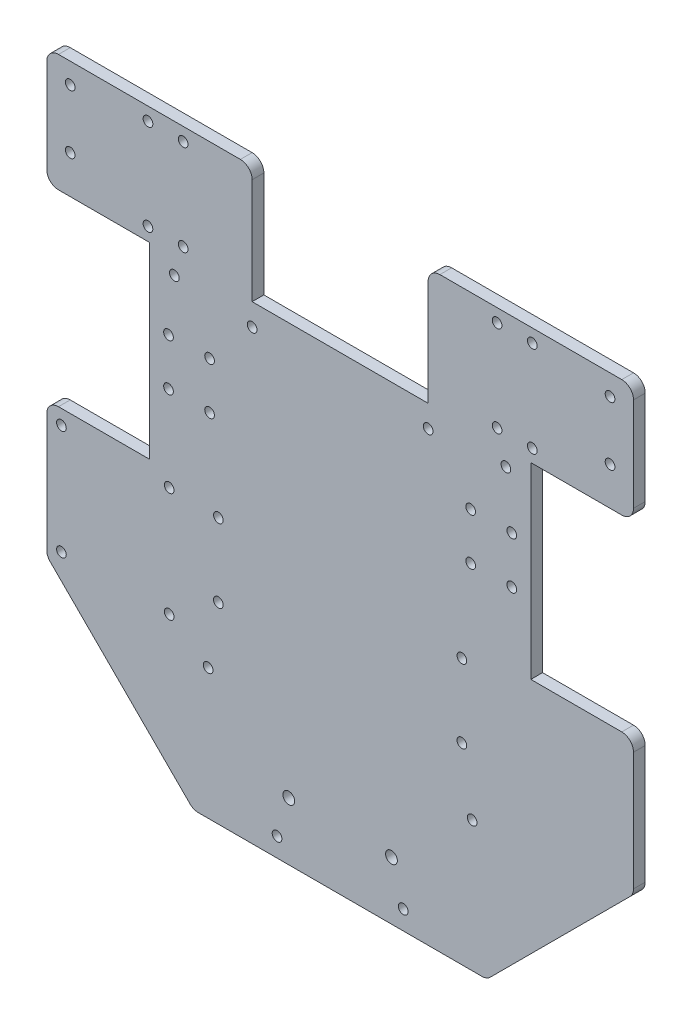
from build123d import *

# Parameters (mm, degrees)
EXTRUDE_1_DEPTH      = 4
SKETCH_4_R           = 1.65
CUT_EXTRUDE_5_DEPTH  = 10
SKETCH_5_R           = 1.65
CUT_EXTRUDE_6_DEPTH  = 10
SKETCH_6_R           = 1.65
CUT_EXTRUDE_7_DEPTH  = 10
SKETCH_7_R           = 1.65
CUT_EXTRUDE_8_DEPTH  = 10
SKETCH_8_R           = 2
CUT_EXTRUDE_9_DEPTH  = 10
SKETCH_9_R           = 1.65
CUT_EXTRUDE_10_DEPTH = 10
SKETCH_10_R          = 1.65
CUT_EXTRUDE_11_DEPTH = 10
SKETCH_11_R          = 1.65
CUT_EXTRUDE_12_DEPTH = 10
SKETCH_12_R          = 1.65
CUT_EXTRUDE_13_DEPTH = 10
FILLET_1_R           = 4
FILLET_2_R           = 4


with BuildPart() as part:
    # 草图1 → 凸台-拉伸1 (new body)
    with BuildSketch(Plane.XY):
        with BuildLine():
            Line((-96, 200), (-30, 200))
            Line((-30, 200), (-30, 160))
            Line((-30, 160), (30, 160))
            Line((30, 160), (30, 200))
            Line((30, 200), (96, 200))
            ThreePointArc((96, 200), (98.828427125, 198.828427125), (100, 196))
            Line((100, 196), (100, 160))
            Line((100, 160), (65, 160))
            Line((65, 160), (65, 96))
            Line((65, 96), (100, 96))
            Line((100, 96), (100, 50))
            Line((100, 50), (50, 0))
            Line((50, 0), (-50, 0))
            Line((-50, 0), (-100, 50))
            Line((-100, 50), (-100, 96))
            Line((-100, 96), (-65, 96))
            Line((-65, 96), (-65, 160))
            Line((-65, 160), (-100, 160))
            Line((-100, 160), (-100, 196))
            ThreePointArc((-100, 196), (-98.828427125, 198.828427125), (-96, 200))
        make_face()
    extrude(amount=EXTRUDE_1_DEPTH)

    # 草图4 → 切除-拉伸5 (cut)
    with BuildSketch(Plane(origin=(0, 0, 0), x_dir=(-1, 0, 0), z_dir=(0, 0, -1))):
        with Locations((56.5, 154.5)):
            Circle(SKETCH_4_R)
        with Locations((-56.5, 154.5)):
            Circle(SKETCH_4_R)
        with Locations((45, 44.5)):
            Circle(SKETCH_4_R)
        with Locations((-45, 44.5)):
            Circle(SKETCH_4_R)
    extrude(amount=-CUT_EXTRUDE_5_DEPTH, mode=Mode.SUBTRACT)

    # 草图5 → 切除-拉伸6 (cut)
    with BuildSketch(Plane(origin=(0, 0, 0), x_dir=(-1, 0, 0), z_dir=(0, 0, -1))):
        with Locations((41.5, 90.5)):
            Circle(SKETCH_5_R)
        with Locations((-41.5, 90.5)):
            Circle(SKETCH_5_R)
        with Locations((41.5, 65.5)):
            Circle(SKETCH_5_R)
        with Locations((-41.5, 65.5)):
            Circle(SKETCH_5_R)
    extrude(amount=-CUT_EXTRUDE_6_DEPTH, mode=Mode.SUBTRACT)

    # 草图6 → 切除-拉伸7 (cut)
    with BuildSketch(Plane(origin=(0, 0, 0), x_dir=(-1, 0, 0), z_dir=(0, 0, -1))):
        with Locations((58.26, 91)):
            Circle(SKETCH_6_R)
        with Locations((95, 91)):
            Circle(SKETCH_6_R)
        with Locations((58.26, 53.62)):
            Circle(SKETCH_6_R)
        with Locations((95, 53.62)):
            Circle(SKETCH_6_R)
    extrude(amount=-CUT_EXTRUDE_7_DEPTH, mode=Mode.SUBTRACT)

    # 草图7 → 切除-拉伸8 (cut)
    with BuildSketch(Plane(origin=(0, 0, 0), x_dir=(-1, 0, 0), z_dir=(0, 0, -1))):
        with Locations((-21.5, 6.5)):
            Circle(SKETCH_7_R)
        with Locations((21.5, 6.5)):
            Circle(SKETCH_7_R)
    extrude(amount=-CUT_EXTRUDE_8_DEPTH, mode=Mode.SUBTRACT)

    # 草图8 → 切除-拉伸9 (cut)
    with BuildSketch(Plane(origin=(0, 0, 0), x_dir=(-1, 0, 0), z_dir=(0, 0, -1))):
        with Locations((-17.5, 19.75)):
            Circle(SKETCH_8_R)
        with Locations((17.5, 19.75)):
            Circle(SKETCH_8_R)
    extrude(amount=-CUT_EXTRUDE_9_DEPTH, mode=Mode.SUBTRACT)

    # 草图9 → 切除-拉伸10 (cut)
    with BuildSketch(Plane(origin=(0, 0, 0), x_dir=(-1, 0, 0), z_dir=(0, 0, -1))):
        with Locations((-30, 152.5)):
            Circle(SKETCH_9_R)
        with Locations((30, 152.5)):
            Circle(SKETCH_9_R)
    extrude(amount=-CUT_EXTRUDE_10_DEPTH, mode=Mode.SUBTRACT)

    # 草图10 → 切除-拉伸11 (cut)
    with BuildSketch(Plane.XY.offset(4)):
        with Locations((-92, 193)):
            Circle(SKETCH_10_R)
        with Locations((-92, 173)):
            Circle(SKETCH_10_R)
        with Locations((92, 173)):
            Circle(SKETCH_10_R)
        with Locations((92, 193)):
            Circle(SKETCH_10_R)
    extrude(amount=-CUT_EXTRUDE_11_DEPTH, mode=Mode.SUBTRACT)

    # 草图11 → 切除-拉伸12 (cut)
    with BuildSketch(Plane.XY.offset(4)):
        with Locations((65.5, 164.5)):
            Circle(SKETCH_11_R)
        with Locations((53.5, 164.5)):
            Circle(SKETCH_11_R)
        with Locations((53.5, 195.5)):
            Circle(SKETCH_11_R)
        with Locations((65.5, 195.5)):
            Circle(SKETCH_11_R)
        with Locations((-65.5, 195.5)):
            Circle(SKETCH_11_R)
        with Locations((-53.5, 195.5)):
            Circle(SKETCH_11_R)
        with Locations((-53.5, 164.5)):
            Circle(SKETCH_11_R)
        with Locations((-65.5, 164.5)):
            Circle(SKETCH_11_R)
    extrude(amount=-CUT_EXTRUDE_12_DEPTH, mode=Mode.SUBTRACT)

    # 草图12 → 切除-拉伸13 (cut)
    with BuildSketch(Plane.XY.offset(4)):
        with Locations((58.5, 120)):
            Circle(SKETCH_12_R)
        with Locations((44.5, 120)):
            Circle(SKETCH_12_R)
        with Locations((44.5, 136)):
            Circle(SKETCH_12_R)
        with Locations((58.5, 136)):
            Circle(SKETCH_12_R)
        with Locations((-58.5, 136)):
            Circle(SKETCH_12_R)
        with Locations((-44.5, 136)):
            Circle(SKETCH_12_R)
        with Locations((-44.5, 120)):
            Circle(SKETCH_12_R)
        with Locations((-58.5, 120)):
            Circle(SKETCH_12_R)
    extrude(amount=-CUT_EXTRUDE_13_DEPTH, mode=Mode.SUBTRACT)

    # 圆角1
    fillet_1_edges = [part.edges().sort_by_distance(p)[0] for p in [
        (100, 160, 2),
        (100, 96, 2),
        (100, 50, 2),
        (50, 0, 2),
        (-50, 0, 2),
        (-100, 50, 2),
        (-100, 96, 2),
        (-100, 160, 2),
    ]]
    fillet(fillet_1_edges, radius=FILLET_1_R)

    # 圆角2
    fillet_2_edges = [part.edges().sort_by_distance(p)[0] for p in [
        (-30, 200, 2),
        (30, 200, 2),
    ]]
    fillet(fillet_2_edges, radius=FILLET_2_R)


solid = part.part
